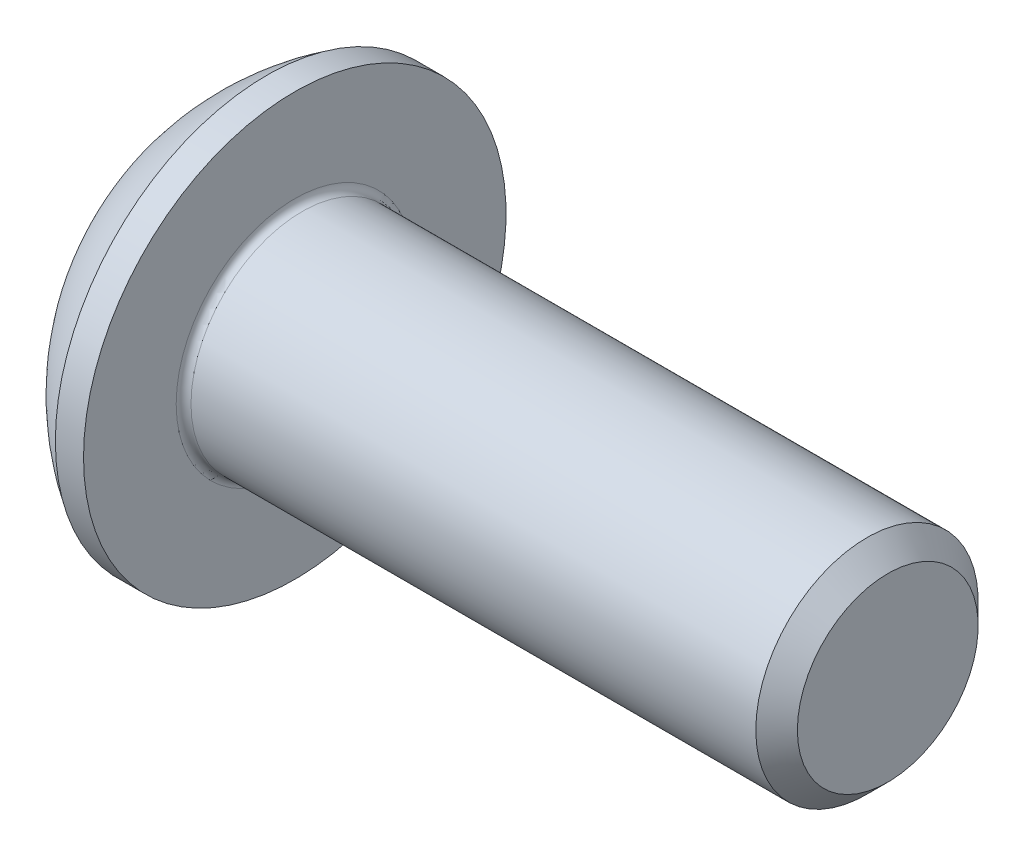
from build123d import *

# Parameters (mm, degrees)
FILLET1_R   = 0.1
HEX_2_DEPTH = 1.04


with BuildPart() as part:
    # BodySke → BaseBody (revolve)
    with BuildSketch(Plane.XY):
        with BuildLine():
            Line((9.65, 0), (9.65, 1.2195))
            Line((9.65, 1.2195), (9.3695, 1.5))
            Line((9.3695, 1.5), (1.65, 1.5))
            Line((1.65, 1.5), (1.65, 2.85))
            Line((1.65, 2.85), (1.27, 2.85))
            ThreePointArc((1.27, 2.85), (0.53140404, 2.229827628), (0, 1.425))
            Line((0, 1.425), (0, 0))
            Line((0, 0), (9.65, 0))
        make_face()
    revolve(axis=Axis((0, 0, 0), (1, 0, 0)))

    # Fillet1
    fillet1_edges = [part.edges().sort_by_distance(p)[0] for p in [
        (1.65, -1.5, 0),
    ]]
    fillet(fillet1_edges, radius=FILLET1_R)

    # Sketch2 → PreBroach (revolve, cut)
    with BuildSketch(Plane.XY):
        Polygon((0, 1), (1.04, 1), (1.617350269, 0), (0, 0), align=None)
    revolve(axis=Axis((0, 0, 0), (1, 0, 0)), mode=Mode.SUBTRACT)

    # Sketch3 → Hex 2 (cut)
    with BuildSketch(Plane(origin=(0, 0, 0), x_dir=(0, 0, -1), z_dir=(1, 0, 0))):
        Polygon((-1, -0.577350269), (-1, 0.577350269), (0, 1.154700538), (1, 0.577350269), (1, -0.577350269), (0, -1.154700538), align=None)
    extrude(amount=HEX_2_DEPTH, mode=Mode.SUBTRACT)


solid = part.part
